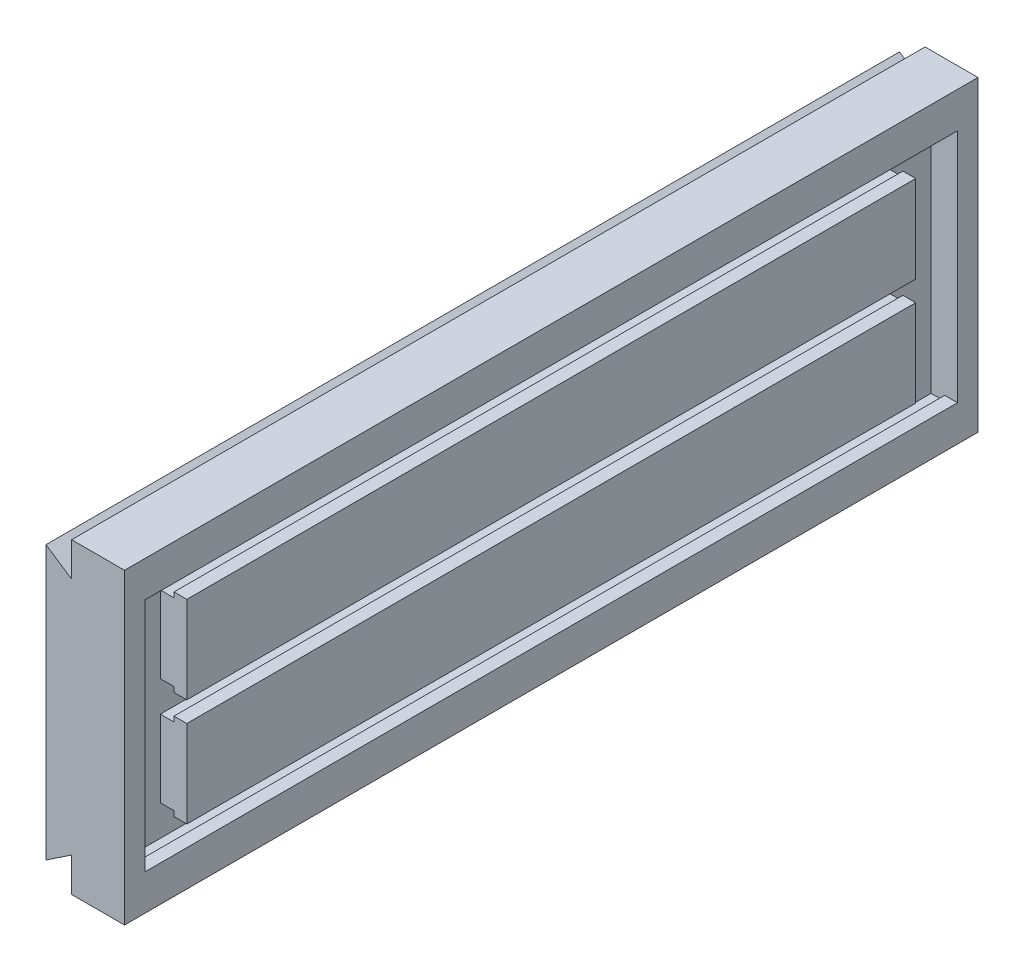
from build123d import *

# Parameters (mm, degrees)
BOSS_EXTRUDE1_DEPTH = 250
CUT_EXTRUDE1_DEPTH  = 238
SKETCH3_W           = 24.5
SKETCH3_H           = 138
CUT_EXTRUDE2_DEPTH  = 15.5


with BuildPart() as part:
    # Sketch1 → Boss-Extrude1 (new body, symmetric)
    with BuildSketch(Plane.XY):
        Polygon((-46, 80), (-46, -80), (-31, -70), (-31, -90), (0, -90), (0, 90), (-31, 90), (-31, 70), align=None)
    extrude(amount=BOSS_EXTRUDE1_DEPTH, both=True)

    # Sketch2 → Cut-Extrude1 (cut, symmetric)
    with BuildSketch(Plane.XY):
        Polygon((0, 69), (-7.5, 69), (-7.5, 72), (-15.5, 72), (-15.5, 54), (-7.5, 54), (-7.5, 57), (0, 57), align=None)
        Polygon((0, 6), (-7.5, 6), (-7.5, 9), (-15.5, 9), (-15.5, -9), (-7.5, -9), (-7.5, -6), (0, -6), align=None)
        Polygon((0, -69), (-7.5, -69), (-7.5, -72), (-15.5, -72), (-15.5, -54), (-7.5, -54), (-7.5, -57), (0, -57), align=None)
    extrude(amount=CUT_EXTRUDE1_DEPTH, both=True, mode=Mode.SUBTRACT)

    # Sketch3 → Cut-Extrude2 (cut)
    with BuildSketch(Plane(origin=(0, 0, 0), x_dir=(0, 0, -1), z_dir=(1, 0, 0))):
        with Locations((-225.75, 0)):
            Rectangle(SKETCH3_W, SKETCH3_H)
        with Locations((225.75, 0)):
            Rectangle(SKETCH3_W, SKETCH3_H)
    extrude(amount=-CUT_EXTRUDE2_DEPTH, mode=Mode.SUBTRACT)


solid = part.part
